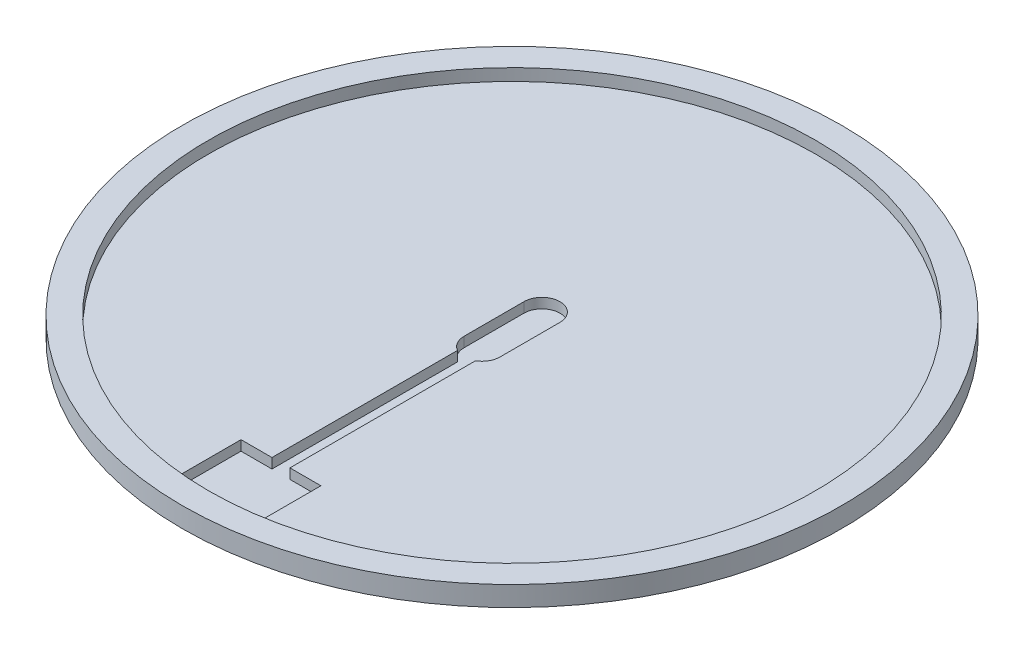
from build123d import *

# Parameters (mm, degrees)
SKETCH2_R           = 165
BOSS_EXTRUDE1_DEPTH = 13
SKETCH3_R           = 165
SKETCH3_R_2         = 149
CUT_EXTRUDE1_DEPTH  = 3
SKETCH4_R           = 152
CUT_EXTRUDE2_DEPTH  = 6
CUT_EXTRUDE3_DEPTH  = 5


with BuildPart() as part:
    # Sketch2 → Boss-Extrude1 (new body)
    with BuildSketch(Plane(origin=(0, 0, 0), x_dir=(1, 0, 0), z_dir=(0, 1, 0))):
        Circle(SKETCH2_R)
    extrude(amount=BOSS_EXTRUDE1_DEPTH)

    # Sketch3 → Cut-Extrude1 (cut)
    with BuildSketch(Plane.XZ):
        Circle(SKETCH3_R)
        Circle(SKETCH3_R_2, mode=Mode.SUBTRACT)
    extrude(amount=-CUT_EXTRUDE1_DEPTH, mode=Mode.SUBTRACT)

    # Sketch4 → Cut-Extrude2 (cut)
    with BuildSketch(Plane(origin=(0, 13, 0), x_dir=(1, 0, 0), z_dir=(0, 1, 0))):
        Circle(SKETCH4_R)
    extrude(amount=-CUT_EXTRUDE2_DEPTH, mode=Mode.SUBTRACT)

    # Sketch5 → Cut-Extrude3 (cut)
    with BuildSketch(Plane(origin=(0, 7, 0), x_dir=(1, 0, 0), z_dir=(0, 1, 0))):
        with BuildLine():
            Line((-4.5, -115.678465615), (-4.5, -22.794228634))
            ThreePointArc((-4.5, -22.794228634), (-7.794228634, -19.5), (-9, -15))
            Line((-9, -15), (-9, 15))
            ThreePointArc((-9, 15), (0, 24), (9, 15))
            Line((9, 15), (9, -15))
            ThreePointArc((9, -15), (7.794228634, -19.5), (4.5, -22.794228634))
            Line((4.5, -22.794228634), (4.5, -115.678465615))
            Line((4.5, -115.678465615), (20, -115.678465615))
            Line((20, -115.678465615), (20, -150.678465615))
            ThreePointArc((20, -150.678465615), (0, -152), (-20, -150.678465615))
            Line((-20, -150.678465615), (-20, -115.678465615))
            Line((-20, -115.678465615), (-4.5, -115.678465615))
        make_face()
    extrude(amount=-CUT_EXTRUDE3_DEPTH, mode=Mode.SUBTRACT)


solid = part.part
